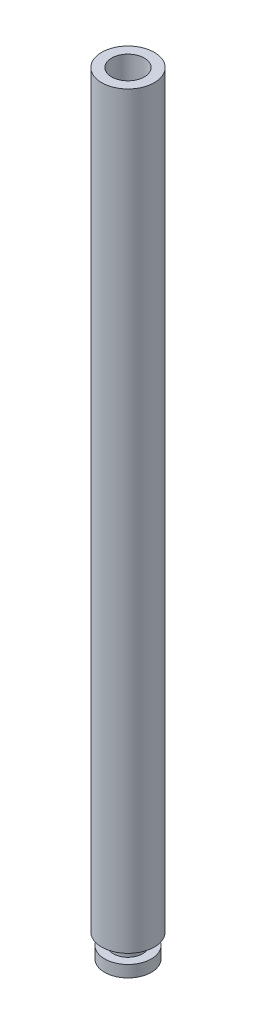
from build123d import *

# Parameters (mm, degrees)
SKETCH1_R           = 2.25
BOSS_EXTRUDE1_DEPTH = 64
SKETCH1_3_R         = 1.375
BOSS_EXTRUDE2_DEPTH = 1
SKETCH5_R           = 1.25
BOSS_EXTRUDE3_DEPTH = 1
SKETCH6_R           = 2
BOSS_EXTRUDE4_DEPTH = 1
SKETCH12_R          = 1.4
CUT_EXTRUDE1_DEPTH  = 7.5


with BuildPart() as part:
    # Sketch1 → Boss-Extrude1 (new body)
    with BuildSketch(Plane(origin=(0, 0, 0), x_dir=(1, 0, 0), z_dir=(0, 1, 0))):
        with Locations((-0.522013312, 0.511138034)):
            Circle(SKETCH1_R)
    extrude(amount=BOSS_EXTRUDE1_DEPTH)

    # Sketch1_3 → Boss-Extrude2 (add)
    with BuildSketch(Plane(origin=(0, 0, 0), x_dir=(1, 0, 0), z_dir=(0, 1, 0))):
        with Locations((-0.522013312, 0.511138034)):
            Circle(SKETCH1_3_R)
    extrude(amount=BOSS_EXTRUDE2_DEPTH)

    # Sketch5 → Boss-Extrude3 (add)
    with BuildSketch(Plane.XZ):
        with Locations((-0.522013312, -0.511138034)):
            Circle(SKETCH5_R)
    extrude(amount=BOSS_EXTRUDE3_DEPTH)

    # Sketch6 → Boss-Extrude4 (add)
    with BuildSketch(Plane.XZ.offset(1)):
        with Locations((-0.522013312, -0.511138034)):
            Circle(SKETCH6_R)
    extrude(amount=BOSS_EXTRUDE4_DEPTH)

    # Sketch12 → Cut-Extrude1 (cut)
    with BuildSketch(Plane(origin=(0, 64, 0), x_dir=(1, 0, 0), z_dir=(0, 1, 0))):
        with Locations((-0.522013312, 0.511138034)):
            Circle(SKETCH12_R)
    extrude(amount=-CUT_EXTRUDE1_DEPTH, mode=Mode.SUBTRACT)


solid = part.part
